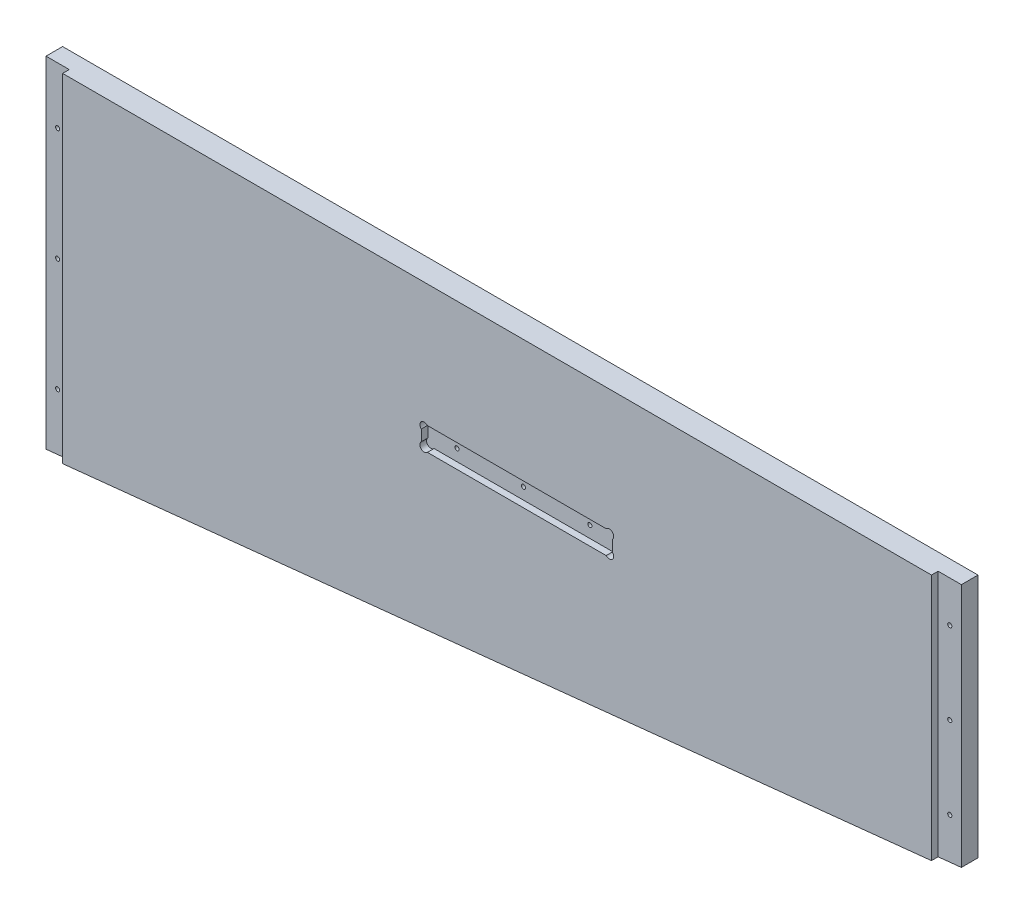
from build123d import *

# Parameters (mm, degrees)
HEADSIDELEFT_THICKNESS_DEPTH      = 17.78
HEADSIDELEFTLEDGE_THICKNESS_DEPTH = 12.7
SKETCH4_W                         = 146.050000002
SKETCH4_H                         = 17.78
CUT_EXTRUDE2_DEPTH                = 5.08
SKETCH6_R                         = 3.302000001
SKETCH6_R_2                       = 3.302
CUT_EXTRUDE3_DEPTH                = 5.08
SKETCH3_R                         = 1.5875
CUT_EXTRUDE1_DEPTH                = 17.78


with BuildPart() as part:
    # HeadSideLeftOutline → HeadSideLeft_Thickness (new body)
    with BuildSketch(Plane.XY):
        Polygon((839.47, -5504.129603175), (839.47, -5314.95), (174.9425, -5314.95), (174.9425, -5573.445396825), align=None)
    extrude(amount=-HEADSIDELEFT_THICKNESS_DEPTH)

    # HeadSideLeftLedge → HeadSideLeftLedge_Thickness (add)
    with BuildSketch(Plane(origin=(0, 0, -17.78), x_dir=(-1, 0, 0), z_dir=(0, 0, -1))):
        Polygon((-174.9425, -5314.95), (-157.1625, -5314.95), (-157.1625, -5575.3), (-174.9425, -5573.445396825), align=None)
        Polygon((-839.47, -5314.95), (-857.25, -5314.95), (-857.25, -5502.275), (-839.47, -5504.129603175), align=None)
    extrude(amount=-HEADSIDELEFTLEDGE_THICKNESS_DEPTH)

    # Sketch4 → Cut-Extrude2 (cut)
    with BuildSketch(Plane.XY):
        with Locations((522.2875, -5417.566000001)):
            Rectangle(SKETCH4_W, SKETCH4_H)
    extrude(amount=-CUT_EXTRUDE2_DEPTH, mode=Mode.SUBTRACT)

    # Sketch6 → Cut-Extrude3 (cut)
    with BuildSketch(Plane.XY):
        with Locations((451.507564029, -5410.921064031)):
            Circle(SKETCH6_R)
        with Locations((451.507564029, -5424.210935971)):
            Circle(SKETCH6_R_2)
        with Locations((593.067435971, -5424.210935971)):
            Circle(SKETCH6_R_2)
        with Locations((593.067435971, -5410.921064031)):
            Circle(SKETCH6_R)
    extrude(amount=-CUT_EXTRUDE3_DEPTH, mode=Mode.SUBTRACT)

    # Sketch3 → Cut-Extrude1 (cut)
    with BuildSketch(Plane.XY):
        with Locations((166.0525, -5531.135582009)):
            Circle(SKETCH3_R)
        with Locations((166.0525, -5444.661349205)):
            Circle(SKETCH3_R)
        with Locations((166.0525, -5358.187116401)):
            Circle(SKETCH3_R)
        with Locations((848.36, -5471.826917991)):
            Circle(SKETCH3_R)
        with Locations((848.36, -5409.076150795)):
            Circle(SKETCH3_R)
        with Locations((848.36, -5346.325383599)):
            Circle(SKETCH3_R)
        with Locations((573.0875, -5417.566)):
            Circle(SKETCH3_R)
        with Locations((522.2875, -5417.566)):
            Circle(SKETCH3_R)
        with Locations((471.4875, -5417.566)):
            Circle(SKETCH3_R)
    extrude(amount=-CUT_EXTRUDE1_DEPTH, mode=Mode.SUBTRACT)


solid = part.part
